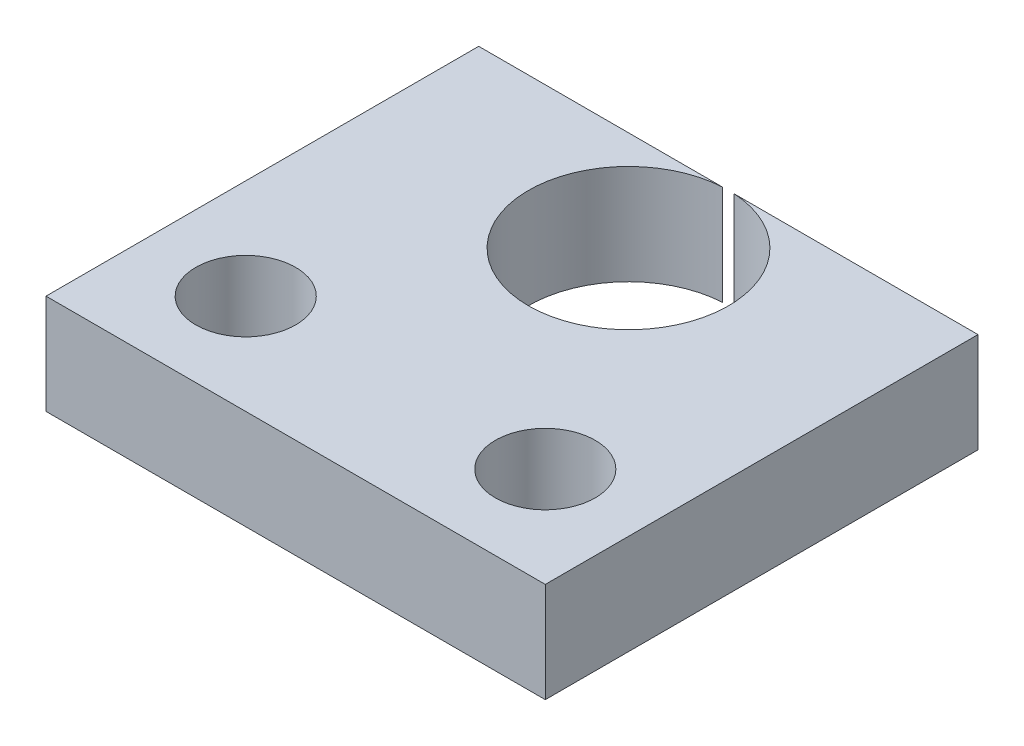
from build123d import *

# Parameters (mm, degrees)
ESQUISSE1_W             = 15
ESQUISSE1_H             = 13
BOSS_EXTRU_1_DEPTH      = 3
ESQUISSE2_R             = 3.005
ESQUISSE2_R_2           = 1.5
ENL_V_MAT_EXTRU_1_DEPTH = 3


with BuildPart() as part:
    # Esquisse1 → Boss.-Extru.1 (new body)
    with BuildSketch(Plane(origin=(0, 0, 0), x_dir=(1, 0, 0), z_dir=(0, 1, 0))):
        with Locations((0, 0.5)):
            Rectangle(ESQUISSE1_W, ESQUISSE1_H)
    extrude(amount=BOSS_EXTRU_1_DEPTH)

    # Esquisse2 → Enlèv. mat.-Extru.1 (cut)
    with BuildSketch(Plane(origin=(0, 3, 0), x_dir=(1, 0, 0), z_dir=(0, 1, 0))):
        with Locations((0, 4)):
            Circle(ESQUISSE2_R)
        with Locations((-4.5, -3)):
            Circle(ESQUISSE2_R_2)
        with Locations((4.5, -3)):
            Circle(ESQUISSE2_R_2)
    extrude(amount=-ENL_V_MAT_EXTRU_1_DEPTH, mode=Mode.SUBTRACT)


solid = part.part
